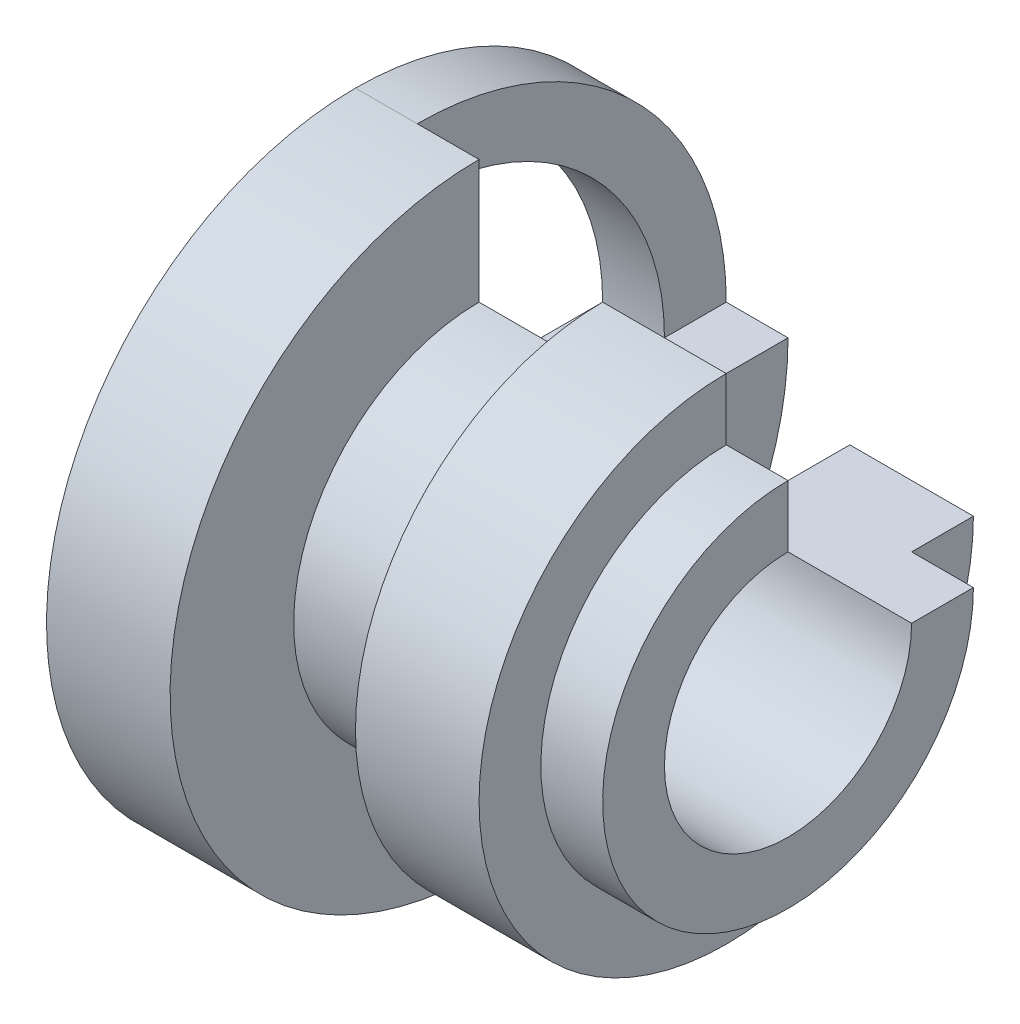
from build123d import *

# Parameters (mm, degrees)
REVOLVE1_ANGLE      = 270
BOSS_EXTRUDE1_DEPTH = 1


with BuildPart() as part:
    # Sketch1 → Revolve1 (revolve)
    with BuildSketch(Plane.XY):
        Polygon((0, 5), (0, 2), (7, 2), (7, 3), (6, 3), (6, 4), (4, 4), (4, 3), (2, 3), (2, 5), align=None)
    revolve(axis=Axis((0, 0, 0), (1, 0, 0)), revolution_arc=REVOLVE1_ANGLE)


with BuildPart() as body_2:
    # Sketch2 → Boss-Extrude1 (new body)
    with BuildSketch(Plane.ZY):
        with BuildLine():
            Line((0, 5), (0, 4))
            ThreePointArc((0, 4), (-2.828427125, 2.828427125), (-4, 0))
            Line((-4, 0), (-5, 0))
            ThreePointArc((-5, 0), (-3.535533906, 3.535533906), (0, 5))
        make_face()
    extrude(amount=-BOSS_EXTRUDE1_DEPTH)


solid = Compound([part.part, body_2.part])
